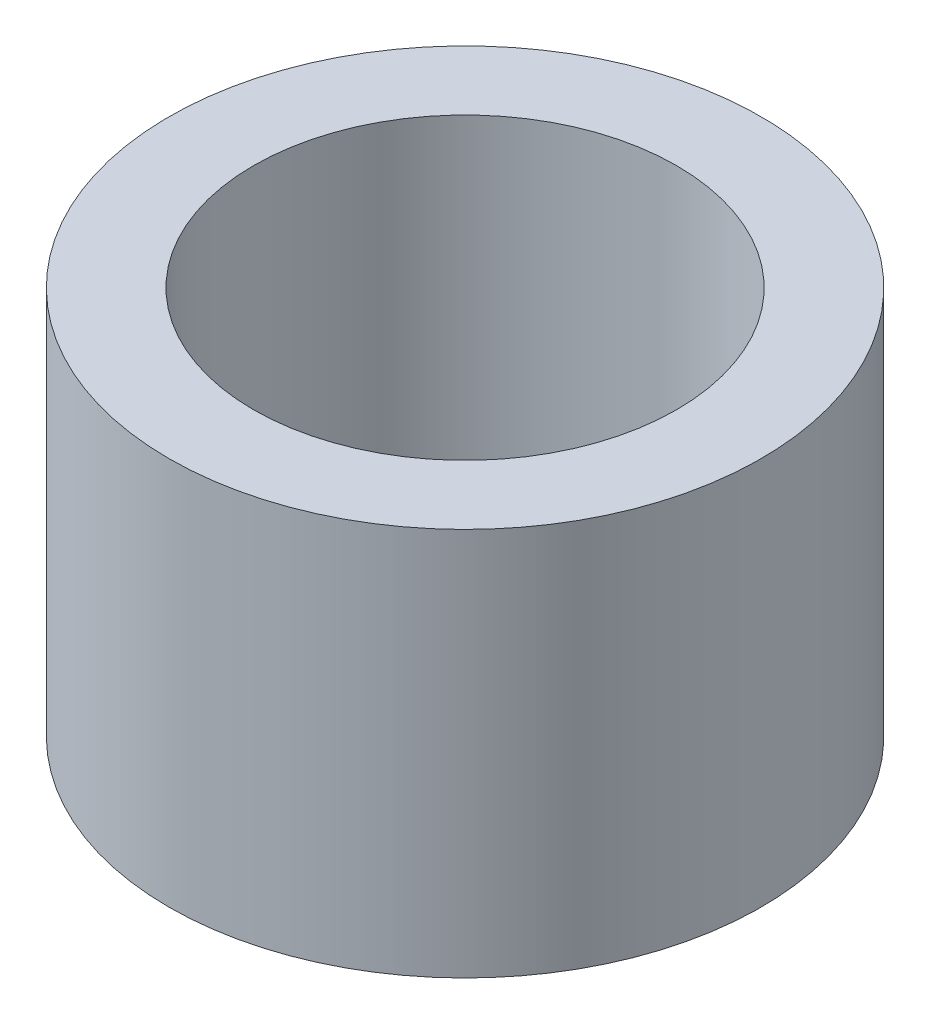
from build123d import *

# Parameters (mm, degrees)
SKETCH1_R           = 11.1125
SKETCH1_R_2         = 7.9375
BOSS_EXTRUDE1_DEPTH = 14.5796


with BuildPart() as part:
    # Sketch1 → Boss-Extrude1 (new body)
    with BuildSketch(Plane(origin=(0, 0, 0), x_dir=(1, 0, 0), z_dir=(0, 1, 0))):
        Circle(SKETCH1_R)
        Circle(SKETCH1_R_2, mode=Mode.SUBTRACT)
    extrude(amount=BOSS_EXTRUDE1_DEPTH)


solid = part.part
